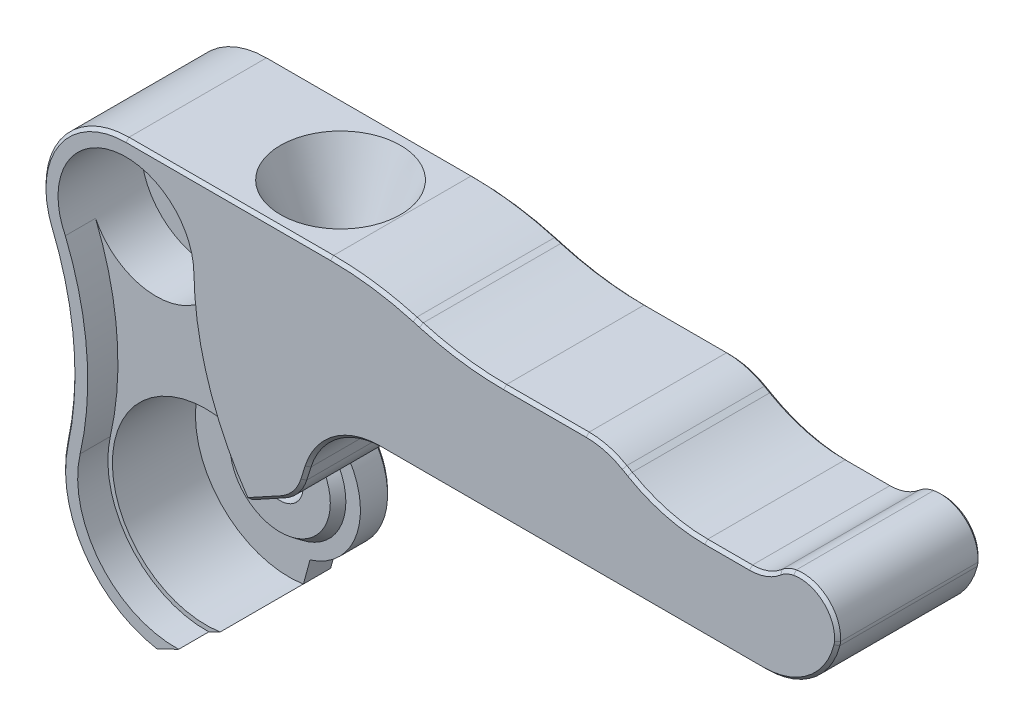
from build123d import *

# Parameters (mm, degrees)
EXTRUDE_1_DEPTH          = 9.5
CUT_EXTRUDE_1_DEPTH      = 2
CUT_EXTRUDE_2_DEPTH      = 5
CUT_EXTRUDE_2_DEPTH_BACK = 5
CHAMFER_3_SIZE           = 0.2
CHAMFER_4_SIZE           = 0.2
CHAMFER_5_SIZE           = 0.2
SKETCH_35_R              = 1.52
CUT_EXTRUDE_3_DEPTH      = 2


with BuildPart() as part:
    # 草图1 → 凸台-拉伸1 (new body)
    with BuildSketch(Plane.XY.offset(14.66)):
        with BuildLine():
            Line((10.013875018, 11.640660484), (26.695757592, 11.640660484))
            ThreePointArc((26.695757592, 11.640660484), (29.763542255, 12.692408053), (31.540712894, 15.405181579))
            ThreePointArc((31.540712894, 15.405181579), (31.567392591, 15.532704372), (31.582905999, 15.662061255))
            ThreePointArc((31.582905999, 15.662061255), (30.767257841, 17.705140503), (28.652721603, 18.311928133))
            ThreePointArc((28.652721603, 18.311928133), (28.148188919, 18.150812525), (27.70363757, 17.86291399))
            ThreePointArc((27.70363757, 17.86291399), (26.793087906, 17.328646623), (25.753839798, 17.142889571))
            Line((25.753839798, 17.142889571), (22.790573212, 17.142889571))
            ThreePointArc((22.790573212, 17.142889571), (20.202578582, 17.48357884), (17.790924351, 18.482432813))
            Line((17.790924351, 18.482432813), (17.43600444, 18.687326732))
            ThreePointArc((17.43600444, 18.687326732), (16.230177325, 19.186753718), (14.93618001, 19.357098353))
            Line((14.93618001, 19.357098353), (9.471737064, 19.357098353))
            ThreePointArc((9.471737064, 19.357098353), (6.685692146, 19.552100152), (3.953975606, 20.133302981))
            Line((3.953975606, 20.133302981), (3.531774948, 20.254486258))
            ThreePointArc((3.531774948, 20.254486258), (0.800058407, 20.835689087), (-1.985986511, 21.030690887))
            Line((-1.985986511, 21.030690887), (-15.538147248, 21.030690887))
            ThreePointArc((-15.538147248, 21.030690887), (-20.108103219, 18.591001725), (-20.623778443, 13.436328132))
            ThreePointArc((-20.623778443, 13.436328132), (-19.195597321, 7.592016854), (-19.570086215, 1.587399156))
            ThreePointArc((-19.570086215, 1.587399156), (-18.531135486, -4.083088818), (-13.775230647, -7.341189744))
            Line((-13.775230647, -7.341189744), (-11.288176227, -6.122720263))
            Line((-11.288176227, -6.122720263), (-10.853623376, -4.518995222))
            ThreePointArc((-10.853623376, -4.518995222), (-7.637616135, -1.077692314), (-8.991428746, 3.433677732))
            Line((-8.991428746, 3.433677732), (-5.185613362, 5.521767908))
            ThreePointArc((-5.185613362, 5.521767908), (-4.30923615, 6.249201579), (-3.767164175, 7.250877543))
            Line((-3.767164175, 7.250877543), (-3.486450124, 8.142372809))
            ThreePointArc((-3.486450124, 8.142372809), (-1.67460917, 10.672320293), (1.282707044, 11.640660484))
            Line((1.282707044, 11.640660484), (10.013875018, 11.640660484))
        make_face()
    extrude(amount=-EXTRUDE_1_DEPTH)

    # 草图2 → 切除-拉伸1 (cut)
    with BuildSketch(Plane.XY.offset(14.66)):
        with BuildLine():
            ThreePointArc((-18.576270357, 1.449716513), (-10.888967052, -6.358042936), (-7.040699486, 3.900932474))
            ThreePointArc((-7.040699486, 3.900932474), (-9.967136502, 9.432986631), (-11.040523791, 15.598657441))
            ThreePointArc((-11.040523791, 15.598657441), (-14.604669497, 11.128277968), (-19.678620032, 13.763131518))
            ThreePointArc((-19.678620032, 13.763131518), (-18.152154257, 7.693736239), (-18.576270357, 1.449716513))
        make_face()
    extrude(amount=-CUT_EXTRUDE_1_DEPTH, mode=Mode.SUBTRACT)

    # 草图7 → 切除-拉伸2 (cut, two sides: drawn at the far end of the back side and taken through both)
    with BuildSketch(Plane.XY.offset(12.16).offset(-CUT_EXTRUDE_2_DEPTH_BACK)):
        with BuildLine():
            Line((-11.093260582, -6.093027877), (-10.743074352, -4.770661757))
            ThreePointArc((-10.743074352, -4.770661757), (-7.437188108, -1.39032296), (-8.426086578, 3.233274564))
            ThreePointArc((-8.426086578, 3.233274564), (-7.84768541, 3.478159198), (-7.255220155, 3.686728888))
            ThreePointArc((-7.255220155, 3.686728888), (-18.011463654, 2.26499609), (-11.093260582, -6.093027877))
        make_face()
    extrude(amount=CUT_EXTRUDE_2_DEPTH + CUT_EXTRUDE_2_DEPTH_BACK, mode=Mode.SUBTRACT)

    # 草图20 → 切除-旋转1 (revolve, cut)
    with BuildSketch(Plane(origin=(0, 15.5, 0), x_dir=(1, 0, 0), z_dir=(0, 1, 0))):
        Polygon((-13.84, -5.16), (-15.54, -5.16), (-15.54, -14.66), (-11.04, -14.66), (-11.04, -9.16), (-13.84, -9.16), align=None)
    revolve(axis=Axis((-15.54, 15.5, 5.16), (0, 0, 1)), mode=Mode.SUBTRACT)

    # 草图28 → 旋转1 (revolve)
    with BuildSketch(Plane(origin=(0, 0, 9.91), x_dir=(-1, 0, 0), z_dir=(0, 0, -1))):
        with BuildLine():
            Line((-15.045898034, 9.140660484), (-14.15, 9.140660484))
            Line((-14.15, 9.140660484), (-14.15, 11.640660484))
            Line((-14.15, 11.640660484), (-18.65, 11.640660484))
            Line((-18.65, 11.640660484), (-18.021509962, 11.424042656))
            ThreePointArc((-18.021509962, 11.424042656), (-17.642565022, 11.188030722), (-17.404086822, 10.81063299))
            ThreePointArc((-17.404086822, 10.81063299), (-16.490704468, 9.600431485), (-15.045898034, 9.140660484))
        make_face()
    revolve(axis=Axis((14.15, 9.140660484, 9.91), (0, 1, 0)))

    # 草图31 → 旋转2 (revolve)
    with BuildSketch(Plane(origin=(0, 0, 0), x_dir=(1, 0, 0), z_dir=(0, 1, 0))):
        Polygon((-8.477724428, -7.16), (-12.24, -7.16), (-12.24, -7.751660878), (-10.2, -7.751660878), (-8.916332066, -7.751660878), align=None)
    revolve(axis=Axis((-12.24, 0, 7.16), (0, 0, 1)))

    # 草图34 → 切除-旋转2 (revolve, cut)
    with BuildSketch(Plane(origin=(-5.952118717, 0.015774741, 0), x_dir=(0, 0, -1), z_dir=(0.9999839503688693, 0.005665598350652085, 0))):
        Polygon((-9.91, 21.068889451), (-9.91, 4.068889451), (-8.61, 4.068889451), (-8.11, 16.068889451), (-5.91, 21.068889451), align=None)
    revolve(axis=Axis((-6.575334536, 110.014009282, 9.91), (0.005665598350652086, -0.9999839503688692, 0)), mode=Mode.SUBTRACT)

    # 倒角3
    chamfer_3_edges = [part.edges().sort_by_distance(p)[0] for p in [
        (31.567392591, 15.532704372, 5.16),
        (29.763542255, 12.692408053, 5.16),
        (30.767257841, 17.705140503, 5.16),
        (28.148188919, 18.150812525, 5.16),
        (26.793087906, 17.328646623, 5.16),
        (24.272206505, 17.142889571, 5.16),
        (20.202578582, 17.48357884, 5.16),
        (17.613464396, 18.584879772, 5.16),
        (16.230177325, 19.186753718, 5.16),
        (12.203958537, 19.357098353, 5.16),
        (6.685692146, 19.552100152, 5.16),
        (3.742875277, 20.19389462, 5.16),
        (0.800058407, 20.835689087, 5.16),
        (-8.762066879, 21.030690887, 5.16),
        (-20.108103219, 18.591001725, 5.16),
        (-19.195597321, 7.592016854, 5.16),
        (-18.531135486, -4.083088818, 5.16),
        (-12.531703437, -6.731955004, 5.16),
        (-11.070899801, -5.320857743, 5.16),
        (-7.637616135, -1.077692314, 5.16),
        (-7.088521054, 4.47772282, 5.16),
        (-4.30923615, 6.249201579, 5.16),
        (-3.626807149, 7.696625176, 5.16),
        (-1.67460917, 10.672320293, 5.16),
        (13.989232318, 11.640660484, 5.16),
    ]]
    chamfer(chamfer_3_edges, length=CHAMFER_3_SIZE)

    # 倒角4
    chamfer_4_edges = [part.edges().sort_by_distance(p)[0] for p in [
        (-17.24, 15.5, 5.16),
    ]]
    chamfer(chamfer_4_edges, length=CHAMFER_4_SIZE)

    # 倒角5
    chamfer_5_edges = [part.edges().sort_by_distance(p)[0] for p in [
        (-18.531135486, -4.083088818, 14.66),
        (-19.195597321, 7.592016854, 14.66),
        (-20.108103219, 18.591001725, 14.66),
        (-8.762066879, 21.030690887, 14.66),
        (0.800058407, 20.835689087, 14.66),
        (3.742875277, 20.19389462, 14.66),
        (6.685692146, 19.552100152, 14.66),
        (12.203958537, 19.357098353, 14.66),
        (16.230177325, 19.186753718, 14.66),
        (17.613464396, 18.584879772, 14.66),
        (20.202578582, 17.48357884, 14.66),
        (24.272206505, 17.142889571, 14.66),
        (26.793087906, 17.328646623, 14.66),
        (28.148188919, 18.150812525, 14.66),
        (30.767257841, 17.705140503, 14.66),
        (31.567392591, 15.532704372, 14.66),
        (29.763542255, 12.692408053, 14.66),
        (13.989232318, 11.640660484, 14.66),
        (-1.67460917, 10.672320293, 14.66),
        (-3.626807149, 7.696625176, 14.66),
        (-4.30923615, 6.249201579, 14.66),
        (-6.270263103, 4.926666401, 14.66),
    ]]
    chamfer(chamfer_5_edges, length=CHAMFER_5_SIZE)

    # 草图35 → 切除-拉伸3 (cut)
    with BuildSketch(Plane.XY.offset(7.751660878)):
        with Locations((-12.24, 0)):
            Circle(SKETCH_35_R)
    extrude(amount=-CUT_EXTRUDE_3_DEPTH, mode=Mode.SUBTRACT)


solid = part.part
